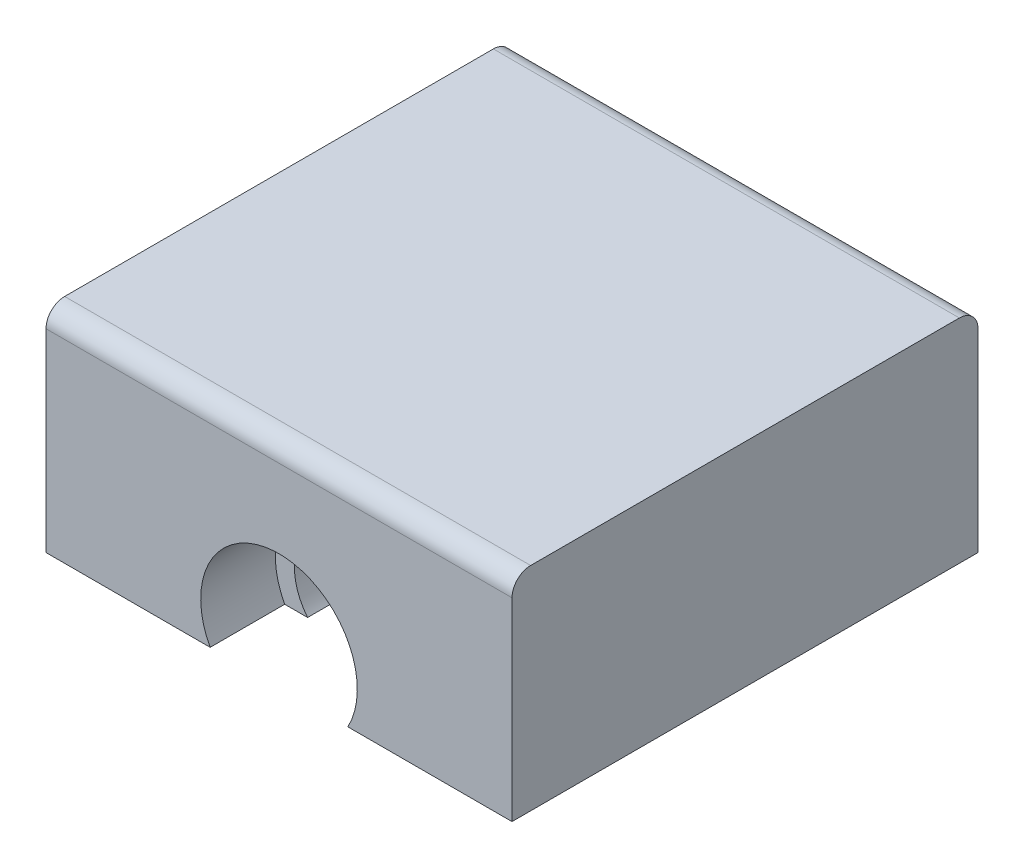
from build123d import *

# Parameters (mm, degrees)
SKETCH1_W           = 12.5
SKETCH1_H           = 12.5
BOSS_EXTRUDE1_DEPTH = 4.7
SKETCH1_2_W         = 12.5
SKETCH1_2_H         = 12.5
BOSS_EXTRUDE2_DEPTH = 1
SKETCH2_R           = 1.5875
CUT_EXTRUDE1_DEPTH  = 4
SKETCH3_R           = 2.1
CUT_EXTRUDE2_DEPTH  = 2
FILLET1_R           = 0.5


with BuildPart() as part:
    # Sketch1 → Boss-Extrude1 (new body)
    with BuildSketch(Plane(origin=(0, 0, 0), x_dir=(1, 0, 0), z_dir=(0, 1, 0))):
        Rectangle(SKETCH1_W, SKETCH1_H)
    extrude(amount=BOSS_EXTRUDE1_DEPTH)

    # Sketch1_2 → Boss-Extrude2 (add)
    with BuildSketch(Plane(origin=(0, 0, 0), x_dir=(1, 0, 0), z_dir=(0, 1, 0))):
        Rectangle(SKETCH1_2_W, SKETCH1_2_H)
    extrude(amount=-BOSS_EXTRUDE2_DEPTH)

    # Sketch2 → Cut-Extrude1 (cut)
    with BuildSketch(Plane.XY.offset(6.25)):
        Circle(SKETCH2_R)
    cut_extrude1 = extrude(amount=-CUT_EXTRUDE1_DEPTH, mode=Mode.SUBTRACT)

    # Sketch3 → Cut-Extrude2 (cut)
    with BuildSketch(Plane.XY.offset(6.25)):
        Circle(SKETCH3_R)
    cut_extrude2 = extrude(amount=-CUT_EXTRUDE2_DEPTH, mode=Mode.SUBTRACT)

    # Mirror1: Cut-Extrude1, Cut-Extrude2 across plane
    add(cut_extrude1.mirror(Plane.XY), mode=Mode.SUBTRACT)
    add(cut_extrude2.mirror(Plane.XY), mode=Mode.SUBTRACT)

    # Fillet1
    fillet1_edges = [part.edges().sort_by_distance(p)[0] for p in [
        (0, 4.7, 6.25),
        (0, 4.7, -6.25),
    ]]
    fillet(fillet1_edges, radius=FILLET1_R)


solid = part.part
